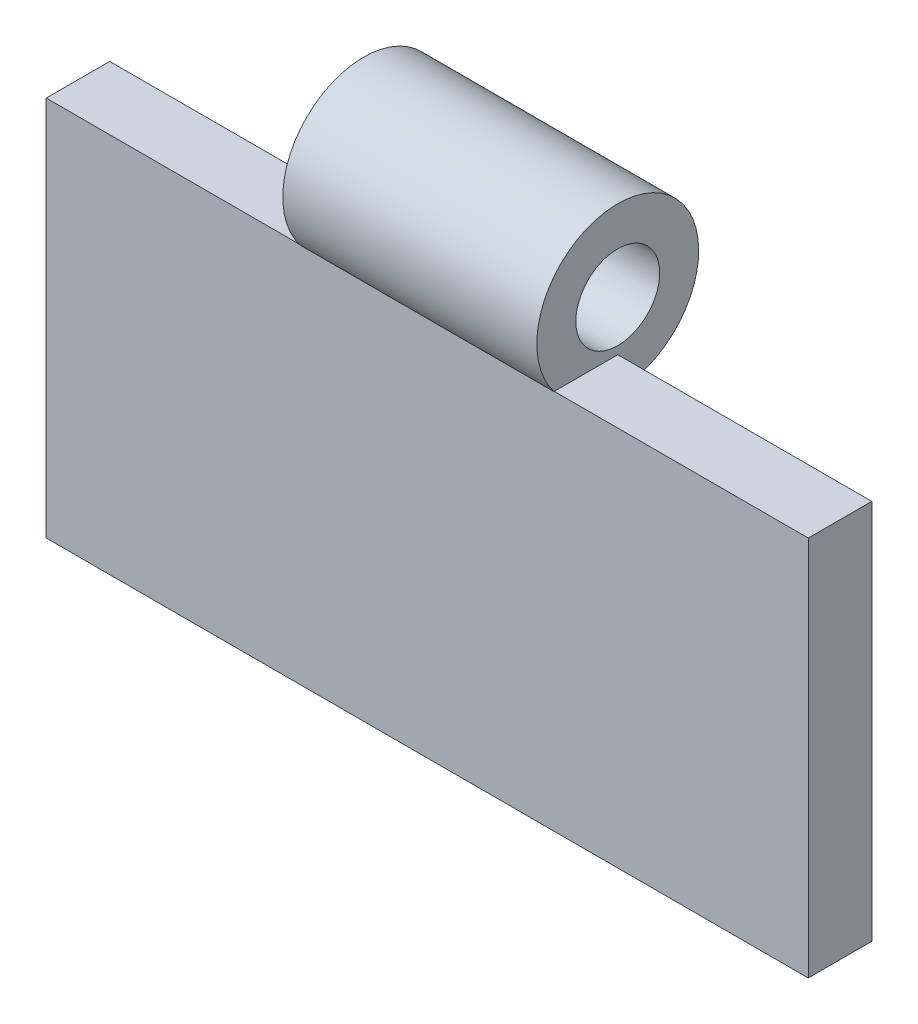
from build123d import *

# Parameters (mm, degrees)
SKETCH1_W           = 60
SKETCH1_H           = 30
BOSS_EXTRUDE1_DEPTH = 5
SKETCH6_R           = 6.374885251
SKETCH6_R_2         = 3.302926723
BOSS_EXTRUDE5_DEPTH = 20


with BuildPart() as part:
    # Sketch1 → Boss-Extrude1 (new body)
    with BuildSketch(Plane.XY):
        with Locations((30, -15)):
            Rectangle(SKETCH1_W, SKETCH1_H)
    extrude(amount=BOSS_EXTRUDE1_DEPTH)

    # Sketch6 → Boss-Extrude5 (add)
    with BuildSketch(Plane.ZY.offset(-20)):
        with Locations((0, 3.924359496)):
            Circle(SKETCH6_R)
        with Locations((0, 3.924359496)):
            Circle(SKETCH6_R_2, mode=Mode.SUBTRACT)
    extrude(amount=-BOSS_EXTRUDE5_DEPTH)


solid = part.part
